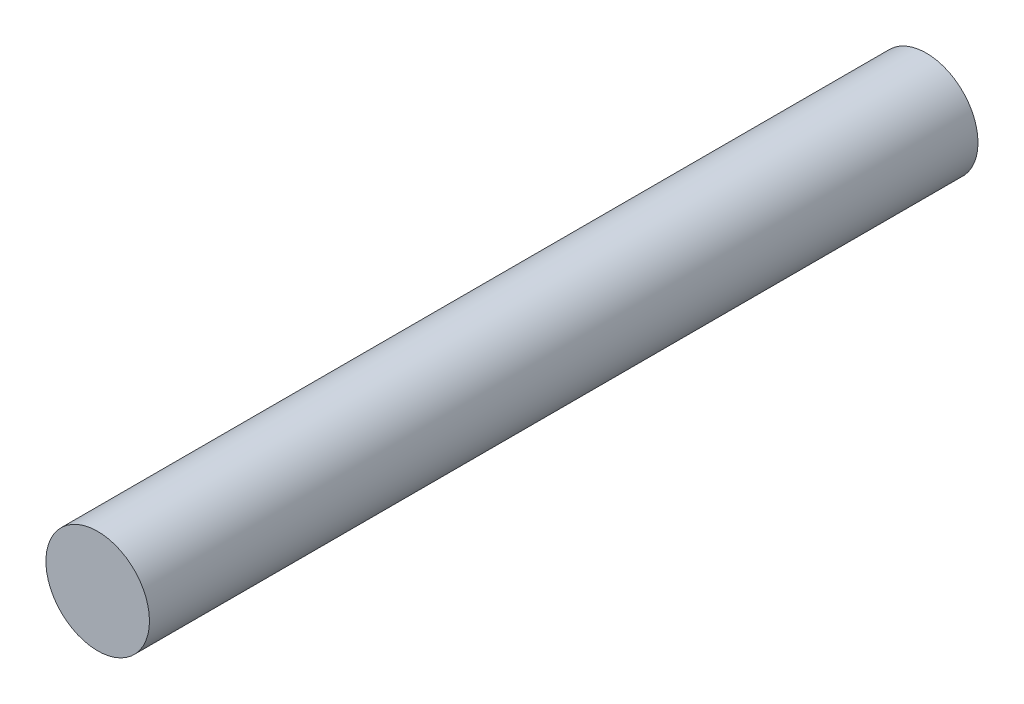
from build123d import *

# Parameters (mm, degrees)
IZIM1_R                     = 2.5
Y_KSEKLIK_EKSTR_ZYON1_DEPTH = 40


with BuildPart() as part:
    # Çizim1 → Yükseklik-Ekstrüzyon1 (new body)
    with BuildSketch(Plane.XY):
        Circle(IZIM1_R)
    extrude(amount=Y_KSEKLIK_EKSTR_ZYON1_DEPTH)


solid = part.part
